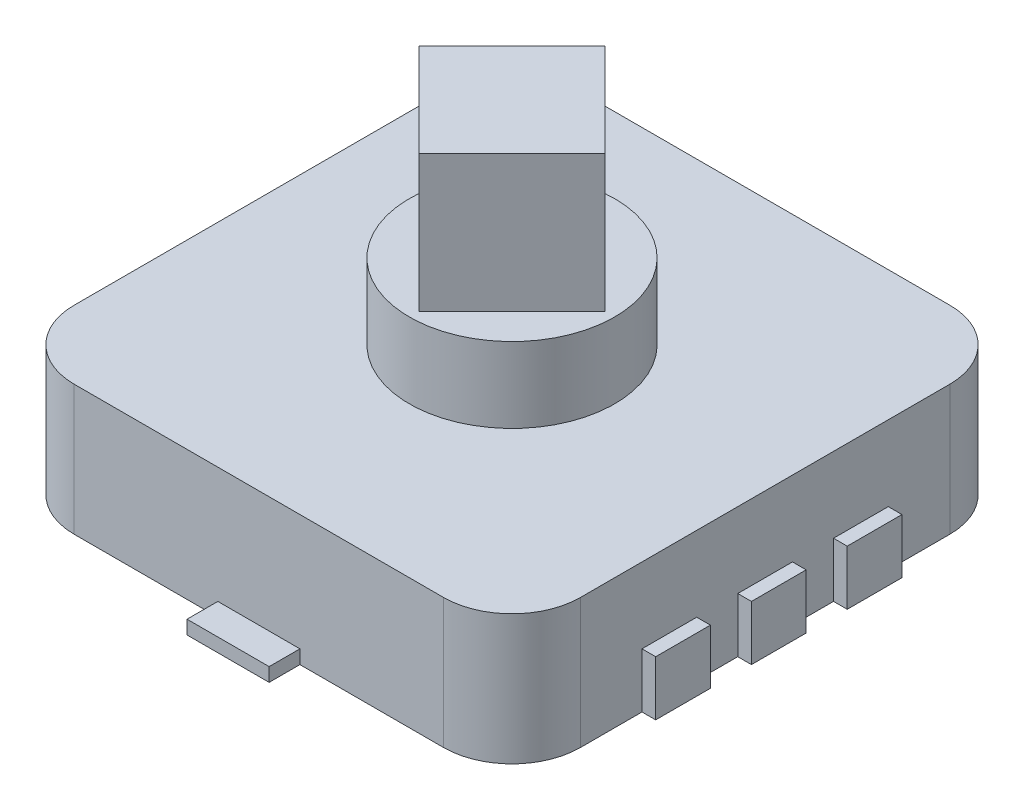
from build123d import *

# Parameters (mm, degrees)
SZKIC2_W                    = 7.4
SZKIC2_H                    = 7.4
DODANIE_WYCI_GNI_CIE1_DEPTH = 1.9
DODANIE_WYCI_GNI_CIE2_START = -1.9
DODANIE_WYCI_GNI_CIE2_DEPTH = 5
DODANIE_WYCI_GNI_CIE3_START = -1.9
SZKIC4_R                    = 1.5
DODANIE_WYCI_GNI_CIE3_DEPTH = 3
SZKIC5_R                    = 0.45
DODANIE_WYCI_GNI_CIE4_DEPTH = 0.5
SZKIC6_W                    = 0.8
SZKIC6_H                    = 0.8
DODANIE_WYCI_GNI_CIE5_DEPTH = 0.2
ZAOKR_GLENIE1_R             = 1
SZKIC7_W                    = 1.2
SZKIC7_H                    = 0.9
DODANIE_WYCI_GNI_CIE6_DEPTH = 0.2


with BuildPart() as part:
    # Szkic2 → Dodanie-wyciągnięcie1 (new body)
    with BuildSketch(Plane(origin=(0, 0, 0), x_dir=(1, 0, 0), z_dir=(0, 1, 0))):
        Rectangle(SZKIC2_W, SZKIC2_H)
    extrude(amount=DODANIE_WYCI_GNI_CIE1_DEPTH)

    # Szkic3 → Dodanie-wyciągnięcie2 (add)
    with BuildSketch(Plane(origin=(0, 1.9, 0), x_dir=(1, 0, 0), z_dir=(0, 1, 0)).offset(DODANIE_WYCI_GNI_CIE2_START)):
        Polygon((0, -1.35764502), (1.35764502, 0), (0, 1.35764502), (-1.35764502, 0), align=None)
    extrude(amount=DODANIE_WYCI_GNI_CIE2_DEPTH)

    # Szkic4 → Dodanie-wyciągnięcie3 (add)
    with BuildSketch(Plane(origin=(0, 1.9, 0), x_dir=(1, 0, 0), z_dir=(0, 1, 0)).offset(DODANIE_WYCI_GNI_CIE3_START)):
        Circle(SZKIC4_R)
    extrude(amount=DODANIE_WYCI_GNI_CIE3_DEPTH)

    # Szkic5 → Dodanie-wyciągnięcie4 (add)
    with BuildSketch(Plane.XZ):
        with Locations((0, 1.9)):
            Circle(SZKIC5_R)
        with Locations((0, -1.9)):
            Circle(SZKIC5_R)
    extrude(amount=DODANIE_WYCI_GNI_CIE4_DEPTH)

    # Szkic6 → Dodanie-wyciągnięcie5 (add)
    with BuildSketch(Plane(origin=(3.7, 0, 0), x_dir=(0, 0, -1), z_dir=(1, 0, 0))):
        with Locations((-1.4, 0.4)):
            Rectangle(SZKIC6_W, SZKIC6_H)
        with Locations((0, 0.4)):
            Rectangle(SZKIC6_W, SZKIC6_H)
        with Locations((1.4, 0.4)):
            Rectangle(SZKIC6_W, SZKIC6_H)
    dodanie_wyci_gni_cie5 = extrude(amount=DODANIE_WYCI_GNI_CIE5_DEPTH)

    # Lustro1: Dodanie-wyciągnięcie5 across plane
    add(dodanie_wyci_gni_cie5.mirror(Plane(origin=(0, 0, 0), x_dir=(0, 0, 1), z_dir=(1, 0, 0))))

    # Zaokrąglenie1
    zaokr_glenie1_edges = [part.edges().sort_by_distance(p)[0] for p in [
        (3.7, 0.95, 3.7),
        (-3.7, 0.95, 3.7),
        (-3.7, 0.95, -3.7),
        (3.7, 0.95, -3.7),
    ]]
    fillet(zaokr_glenie1_edges, radius=ZAOKR_GLENIE1_R)

    # Szkic7 → Dodanie-wyciągnięcie6 (add)
    with BuildSketch(Plane.XZ):
        with Locations((0, 3.7)):
            Rectangle(SZKIC7_W, SZKIC7_H)
        with Locations((0, -3.7)):
            Rectangle(SZKIC7_W, SZKIC7_H)
    extrude(amount=-DODANIE_WYCI_GNI_CIE6_DEPTH)


solid = part.part
